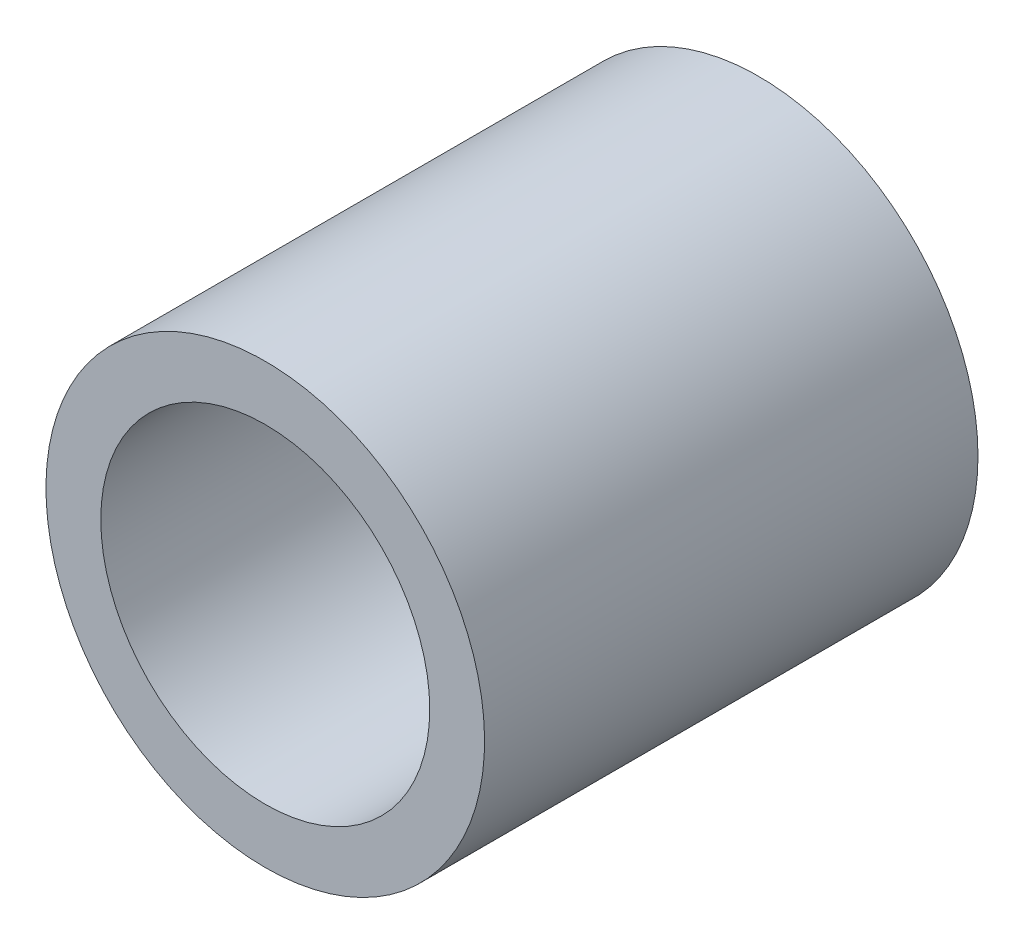
from build123d import *

# Parameters (mm, degrees)
SKETCH1_R          = 12.7
BASE_EXTRUDE_DEPTH = 28.575
SKETCH2_R          = 9.525
CUT_EXTRUDE1_DEPTH = 29.575


with BuildPart() as part:
    # Sketch1 → Base-Extrude (new body)
    with BuildSketch(Plane.XY):
        Circle(SKETCH1_R)
    extrude(amount=BASE_EXTRUDE_DEPTH)

    # Sketch2 → Cut-Extrude1 (cut, through all)
    with BuildSketch(Plane.XY.offset(28.575)):
        Circle(SKETCH2_R)
    extrude(amount=-CUT_EXTRUDE1_DEPTH, mode=Mode.SUBTRACT)


solid = part.part
